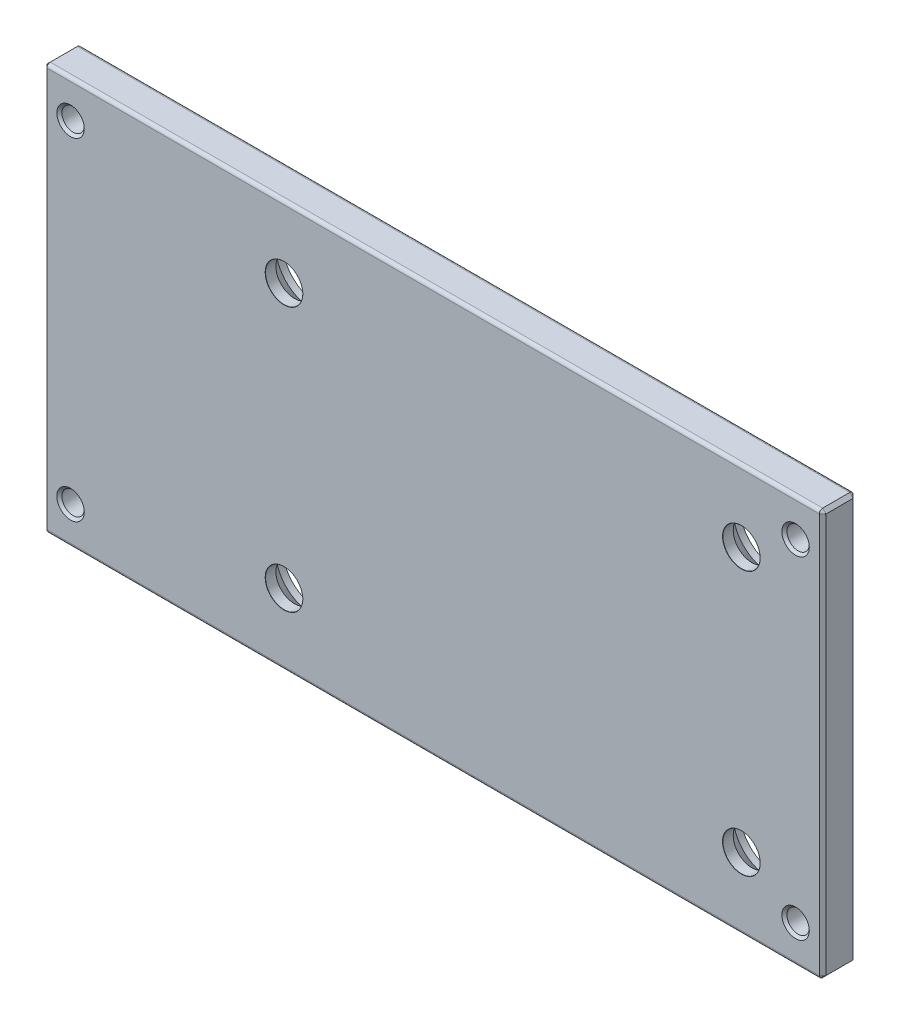
from build123d import *

# Parameters (mm, degrees)
SKETCH1_W                                    = 5
SKETCH1_H                                    = 60
BOSS_EXTRUDE1_DEPTH                          = 57.5
M4_TAPPED_HOLE1_AT_2_COUNT                   = 2
M4_TAPPED_HOLE1_AT_2_PITCH                   = 107
M4_TAPPED_HOLE1_AT_3_COUNT                   = 2
M4_TAPPED_HOLE1_AT_3_PITCH                   = 49
M4_TAPPED_HOLE1_AT_4_COUNT                   = 2
M4_TAPPED_HOLE1_AT_4_PITCH                   = 117.686022959
CSK_FOR_M5_COUNTERSUNK_FLAT_HEAD_SCR_2_COUNT = 2
CSK_FOR_M5_COUNTERSUNK_FLAT_HEAD_SCR_2_PITCH = 77.956718761
CSK_FOR_M5_COUNTERSUNK_FLAT_HEAD_SCR_3_COUNT = 2
CSK_FOR_M5_COUNTERSUNK_FLAT_HEAD_SCR_3_PITCH = 67.5
CSK_FOR_M5_COUNTERSUNK_FLAT_HEAD_SCR_4_COUNT = 2
CSK_FOR_M5_COUNTERSUNK_FLAT_HEAD_SCR_4_PITCH = 39
FILLET1_R                                    = 0.5
CHAMFER1_SIZE                                = 0.5


with BuildPart() as part:
    # Sketch1 → Boss-Extrude1 (new body, symmetric)
    with BuildSketch(Plane(origin=(0, 0, 0), x_dir=(0, 0, -1), z_dir=(1, 0, 0))):
        Rectangle(SKETCH1_W, SKETCH1_H)
    extrude(amount=BOSS_EXTRUDE1_DEPTH, both=True)

    # Sketch3 → M4 Tapped Hole1 (revolve, cut)
    with BuildSketch(Plane(origin=(-53.5, 24.5, 2.5), x_dir=(0, -1, 0), z_dir=(1, 0, 0))):
        Polygon((0, 0), (0, 5), (2.025, 5), (1.65, 4.625), (1.65, 0.375), (2.025, 0), align=None)
    m4_tapped_hole1 = revolve(axis=Axis((-53.5, 24.5, 8.85), (0, 0, -1)), mode=Mode.SUBTRACT)

    # M4 Tapped Hole1 at 2: M4 Tapped Hole1 ×2
    with Locations(*[(i * M4_TAPPED_HOLE1_AT_2_PITCH, 0, 0) for i in range(1, M4_TAPPED_HOLE1_AT_2_COUNT)]):
        add(m4_tapped_hole1, mode=Mode.SUBTRACT)

    # M4 Tapped Hole1 at 3: M4 Tapped Hole1 ×2
    with Locations(*[(0, -i * M4_TAPPED_HOLE1_AT_3_PITCH, 0) for i in range(1, M4_TAPPED_HOLE1_AT_3_COUNT)]):
        add(m4_tapped_hole1, mode=Mode.SUBTRACT)

    # M4 Tapped Hole1 at 4: M4 Tapped Hole1 ×2
    with Locations(*[Vector(0.909198878, -0.416362103, 0) * (i * M4_TAPPED_HOLE1_AT_4_PITCH) for i in range(1, M4_TAPPED_HOLE1_AT_4_COUNT)]):
        add(m4_tapped_hole1, mode=Mode.SUBTRACT)

    # Sketch6 → CSK for M5 Countersunk Flat Head Screw1 (revolve, cut)
    with BuildSketch(Plane(origin=(-22, 19.5, -2.5), x_dir=(0, 1, 0), z_dir=(1, 0, 0))):
        Polygon((0, 0), (0, 5), (2.775, 5), (2.75, 4.975), (2.75, 3.45), (5.2, 1), (5.2, 0), align=None)
    csk_for_m5_countersunk_flat_head_screw1 = revolve(axis=Axis((-22, 19.5, -8.85), (0, 0, 1)), mode=Mode.SUBTRACT)

    # CSK for M5 Countersunk Flat Head Scr 2: CSK for M5 Countersunk Flat Head Screw1 ×2
    with Locations(*[Vector(0.865865073, -0.500277598, 0) * (i * CSK_FOR_M5_COUNTERSUNK_FLAT_HEAD_SCR_2_PITCH) for i in range(1, CSK_FOR_M5_COUNTERSUNK_FLAT_HEAD_SCR_2_COUNT)]):
        add(csk_for_m5_countersunk_flat_head_screw1, mode=Mode.SUBTRACT)

    # CSK for M5 Countersunk Flat Head Scr 3: CSK for M5 Countersunk Flat Head Screw1 ×2
    with Locations(*[(i * CSK_FOR_M5_COUNTERSUNK_FLAT_HEAD_SCR_3_PITCH, 0, 0) for i in range(1, CSK_FOR_M5_COUNTERSUNK_FLAT_HEAD_SCR_3_COUNT)]):
        add(csk_for_m5_countersunk_flat_head_screw1, mode=Mode.SUBTRACT)

    # CSK for M5 Countersunk Flat Head Scr 4: CSK for M5 Countersunk Flat Head Screw1 ×2
    with Locations(*[(0, -i * CSK_FOR_M5_COUNTERSUNK_FLAT_HEAD_SCR_4_PITCH, 0) for i in range(1, CSK_FOR_M5_COUNTERSUNK_FLAT_HEAD_SCR_4_COUNT)]):
        add(csk_for_m5_countersunk_flat_head_screw1, mode=Mode.SUBTRACT)

    # Fillet1
    fillet1_edges = [part.edges().sort_by_distance(p)[0] for p in [
        (0, -30, -2.5),
        (0, -30, 2.5),
        (0, 30, 2.5),
        (0, 30, -2.5),
    ]]
    fillet(fillet1_edges, radius=FILLET1_R)

    # Chamfer1
    chamfer1_edges = [part.edges().sort_by_distance(p)[0] for p in [
        (-57.5, 0, -2.5),
        (57.5, 0, -2.5),
        (-57.5, -30, 0),
        (-57.5, 0, 2.5),
        (-57.5, 30, 0),
        (-57.5, 29.853553391, 2.353553391),
        (-57.5, 29.853553391, -2.353553391),
        (-57.5, -29.853553391, 2.353553391),
        (-57.5, -29.853553391, -2.353553391),
        (57.5, -30, 0),
        (57.5, 30, 0),
        (57.5, 0, 2.5),
        (57.5, 29.853553391, 2.353553391),
        (57.5, 29.853553391, -2.353553391),
        (57.5, -29.853553391, 2.353553391),
        (57.5, -29.853553391, -2.353553391),
    ]]
    chamfer(chamfer1_edges, length=CHAMFER1_SIZE)


solid = part.part
